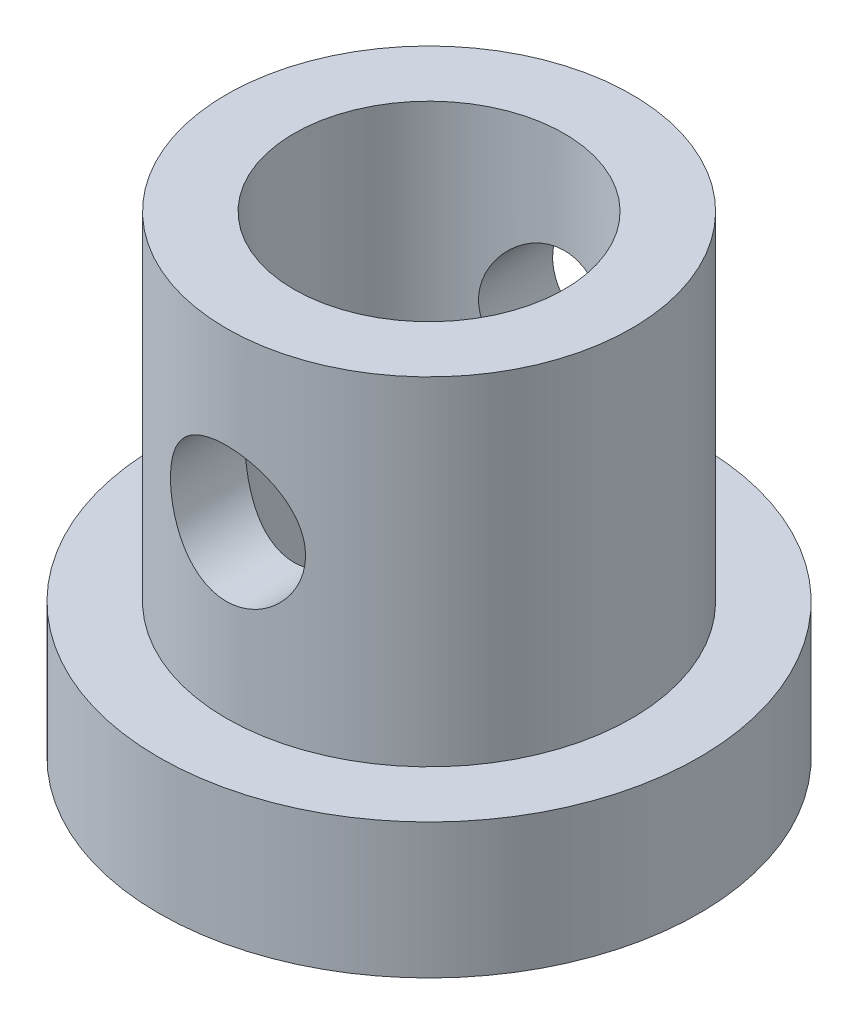
from build123d import *

# Parameters (mm, degrees)
SKETCH1_R           = 4
SKETCH1_R_2         = 2
BOSS_EXTRUDE1_DEPTH = 2
SKETCH2_R           = 3
SKETCH2_R_2         = 2
BOSS_EXTRUDE2_DEPTH = 5
SKETCH3_R           = 1
CUT_EXTRUDE1_DEPTH  = 12.5


with BuildPart() as part:
    # Sketch1 → Boss-Extrude1 (new body)
    with BuildSketch(Plane(origin=(0, 0, 0), x_dir=(1, 0, 0), z_dir=(0, 1, 0))):
        Circle(SKETCH1_R)
        Circle(SKETCH1_R_2, mode=Mode.SUBTRACT)
    extrude(amount=BOSS_EXTRUDE1_DEPTH)

    # Sketch2 → Boss-Extrude2 (add)
    with BuildSketch(Plane(origin=(0, 2, 0), x_dir=(1, 0, 0), z_dir=(0, 1, 0))):
        Circle(SKETCH2_R)
        Circle(SKETCH2_R_2, mode=Mode.SUBTRACT)
    extrude(amount=BOSS_EXTRUDE2_DEPTH)

    # Sketch3 → Cut-Extrude1 (cut, symmetric)
    with BuildSketch(Plane.XY):
        with Locations((0, 4.5)):
            Circle(SKETCH3_R)
    extrude(amount=CUT_EXTRUDE1_DEPTH, both=True, mode=Mode.SUBTRACT)


solid = part.part
